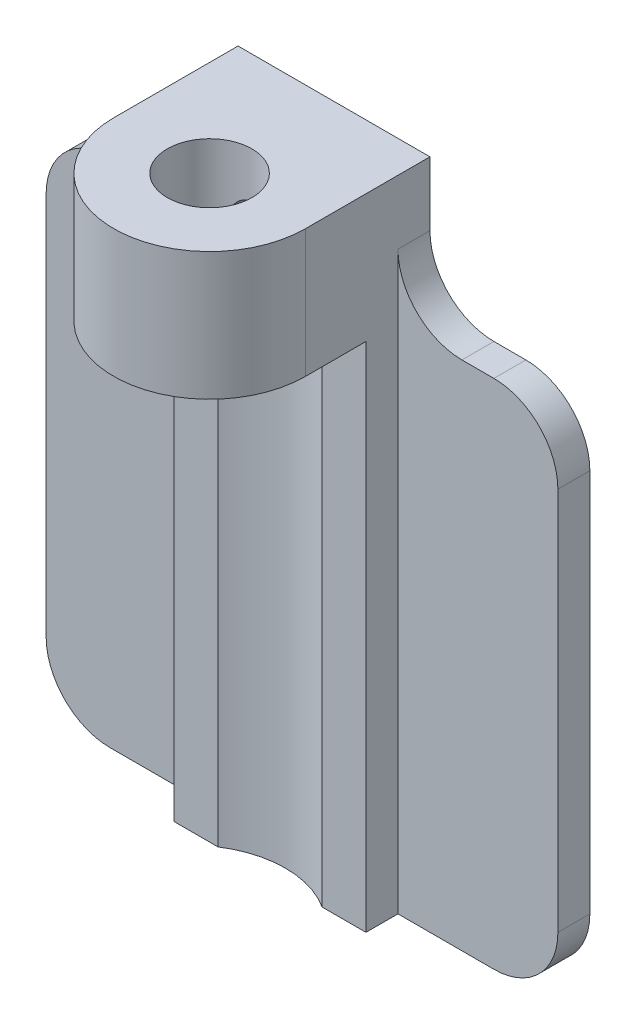
from build123d import *

# Parameters (mm, degrees)
BOSS_EXTRUDE1_DEPTH        = 4.7625
SKETCH3_R                  = 2.1
CUT_EXTRUDE1_DEPTH         = 33.69364665
SKETCH4_R                  = 4.7625
CUT_EXTRUDE2_DEPTH         = 25.4
SKETCH5_W                  = 10.115932276
SKETCH5_H                  = 25.4
BOSS_EXTRUDE2_DEPTH        = 1.5875
SKETCH6_OUTSIDE_W          = 35.822
SKETCH6_OUTSIDE_H          = 21.36
SKETCH6_OUTSIDE_R          = 4.7625
CUT_EXTRUDE3_DEPTH         = 3.175
CUT_EXTRUDE4_DEPTH         = 32.87399018
BOSS_EXTRUDE3_DEPTH        = 3.175
FILLET2_R                  = 3.175
F_2_56_TAPPED_HOLE1_REACH  = 27.374
F_2_56_TAPPED_HOLE1_BORE_R = 0.889


with BuildPart() as part:
    # Sketch2 → Boss-Extrude1 (new, symmetric)
    with BuildSketch(Plane(origin=(0, 0, 0), x_dir=(0, 0, -1), z_dir=(1, 0, 0))):
        Polygon((-4.7625, 12.7), (3, 12.7), (3, -12.7), (6.175, -12.7), (6.175, 19.05), (-4.7625, 19.05), align=None)
    extrude(amount=BOSS_EXTRUDE1_DEPTH, both=True)

    # Sketch3 → Cut-Extrude1 (cut, through all)
    with BuildSketch(Plane(origin=(0, 19.05, 0), x_dir=(1, 0, 0), z_dir=(0, 1, 0))):
        with Locations(Location((0, 0, 0), (0, 0, 270))):
            Circle(SKETCH3_R)
    extrude(amount=-CUT_EXTRUDE1_DEPTH, mode=Mode.SUBTRACT)

    # Sketch4 → Cut-Extrude2 (cut)
    with BuildSketch(Plane.XZ.offset(12.7)):
        with Locations((0, 1.0005)):
            Circle(SKETCH4_R)
    extrude(amount=-CUT_EXTRUDE2_DEPTH, mode=Mode.SUBTRACT)

    # Sketch5 → Boss-Extrude2 (add)
    with BuildSketch(Plane(origin=(0, 0, -6.175), x_dir=(-1, 0, 0), z_dir=(0, 0, -1))):
        with Locations((-7.642033862, 0)):
            Rectangle(SKETCH5_W, SKETCH5_H)
        with Locations((7.642033862, 0)):
            Rectangle(SKETCH5_W, SKETCH5_H)
    extrude(amount=-BOSS_EXTRUDE2_DEPTH)

    # Sketch6 outside → Cut-Extrude3 (cut)
    with BuildSketch(Plane(origin=(0, 19.05, 0), x_dir=(1, 0, 0), z_dir=(0, 1, 0))):
        with Locations((0, 0.706)):
            Rectangle(SKETCH6_OUTSIDE_W, SKETCH6_OUTSIDE_H)
        with Locations(Location((0, 0, 0), (0, 0, 270))):
            Circle(SKETCH6_OUTSIDE_R, mode=Mode.SUBTRACT)
    extrude(amount=-CUT_EXTRUDE3_DEPTH, mode=Mode.SUBTRACT)

    # Sketch7 → Cut-Extrude4 (cut, through all)
    with BuildSketch(Plane(origin=(0, 15.875, 0), x_dir=(1, 0, 0), z_dir=(0, 1, 0))):
        with BuildLine():
            ThreePointArc((0, -4.7625), (-3.367596045, -3.367596045), (-4.7625, 0))
            Line((-4.7625, 0), (-4.7625, -4.7625))
            Line((-4.7625, -4.7625), (0, -4.7625))
        make_face()
        with BuildLine():
            ThreePointArc((4.7625, 0), (3.367596045, -3.367596045), (0, -4.7625))
            Line((0, -4.7625), (4.7625, -4.7625))
            Line((4.7625, -4.7625), (4.7625, 0))
        make_face()
    extrude(amount=-CUT_EXTRUDE4_DEPTH, mode=Mode.SUBTRACT)

    # Sketch8 → Boss-Extrude3 (add)
    with BuildSketch(Plane(origin=(0, 15.875, 0), x_dir=(1, 0, 0), z_dir=(0, 1, 0))):
        with BuildLine():
            Line((4.7625, 6.175), (4.7625, 0))
            ThreePointArc((4.7625, 0), (0, 4.7625), (-4.7625, 0))
            Line((-4.7625, 0), (-4.7625, 6.175))
            Line((-4.7625, 6.175), (4.7625, 6.175))
        make_face()
    extrude(amount=BOSS_EXTRUDE3_DEPTH)

    # Fillet2
    fillet2_edges = [part.edges().sort_by_distance(p)[0] for p in [
        (-4.7625, 12.7, -5.38125),
        (-12.7, -12.7, -5.38125),
        (-12.7, 12.7, -5.38125),
        (4.7625, 12.7, -5.38125),
        (12.7, -12.7, -5.38125),
        (12.7, 12.7, -5.38125),
    ]]
    fillet(fillet2_edges, radius=FILLET2_R)

    # #2-56 Tapped Hole1 bore → #2-56 Tapped Hole1 (cut, up to next)
    with BuildSketch(Plane(origin=(0, 0, -6.175), x_dir=(-1, 0, 0), z_dir=(0, 0, -1)), mode=Mode.PRIVATE) as f_2_56_tapped_hole1_sk1:
        with Locations((0, 15.875)):
            Circle(F_2_56_TAPPED_HOLE1_BORE_R)
    f_2_56_tapped_hole1_tool1 = extrude(f_2_56_tapped_hole1_sk1.sketch, amount=-F_2_56_TAPPED_HOLE1_REACH, mode=Mode.PRIVATE) & part.part
    add(f_2_56_tapped_hole1_tool1.solids().sort_by_distance((0, 15.875, -6.175))[0], mode=Mode.SUBTRACT)


solid = part.part
